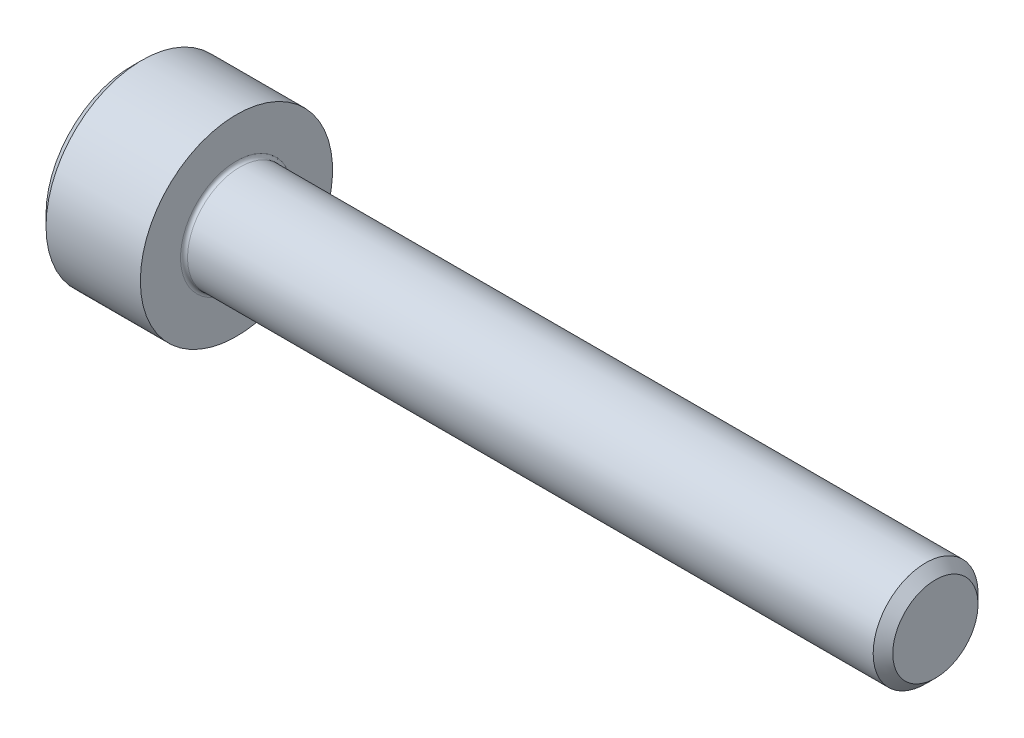
from build123d import *

# Parameters (mm, degrees)
FILLET1_R   = 0.1
HEX_2_DEPTH = 1.3


with BuildPart() as part:
    # BodySke → Base-Revolve (revolve)
    with BuildSketch(Plane.XY):
        Polygon((0, 0), (0, 2.45), (0.3, 2.75), (3, 2.75), (3, 1.5), (22.7195, 1.5), (23, 1.2195), (23, 0), align=None)
    revolve(axis=Axis((-31.75, 0, 0), (1, 0, 0)))

    # Fillet1
    fillet1_edges = [part.edges().sort_by_distance(p)[0] for p in [
        (3, -1.5, 0),
    ]]
    fillet(fillet1_edges, radius=FILLET1_R)

    # Sketch2 → Hex-PreBroach (revolve, cut)
    with BuildSketch(Plane.XY):
        Polygon((0, 1.28), (1.3, 1.28), (2.039008345, 0), (0, 0), align=None)
    revolve(axis=Axis((0, 0, 0), (1, 0, 0)), mode=Mode.SUBTRACT)

    # Sketch3 → Hex 2 (cut)
    with BuildSketch(Plane(origin=(0, 0, 0), x_dir=(0, 0.5, 0.866025404), z_dir=(-1, 0, 0))):
        Polygon((0.739008345, 1.28), (-0.739008345, 1.28), (-1.478016689, 0), (-0.739008345, -1.28), (0.739008345, -1.28), (1.478016689, 0), align=None)
    extrude(amount=-HEX_2_DEPTH, mode=Mode.SUBTRACT)


solid = part.part
